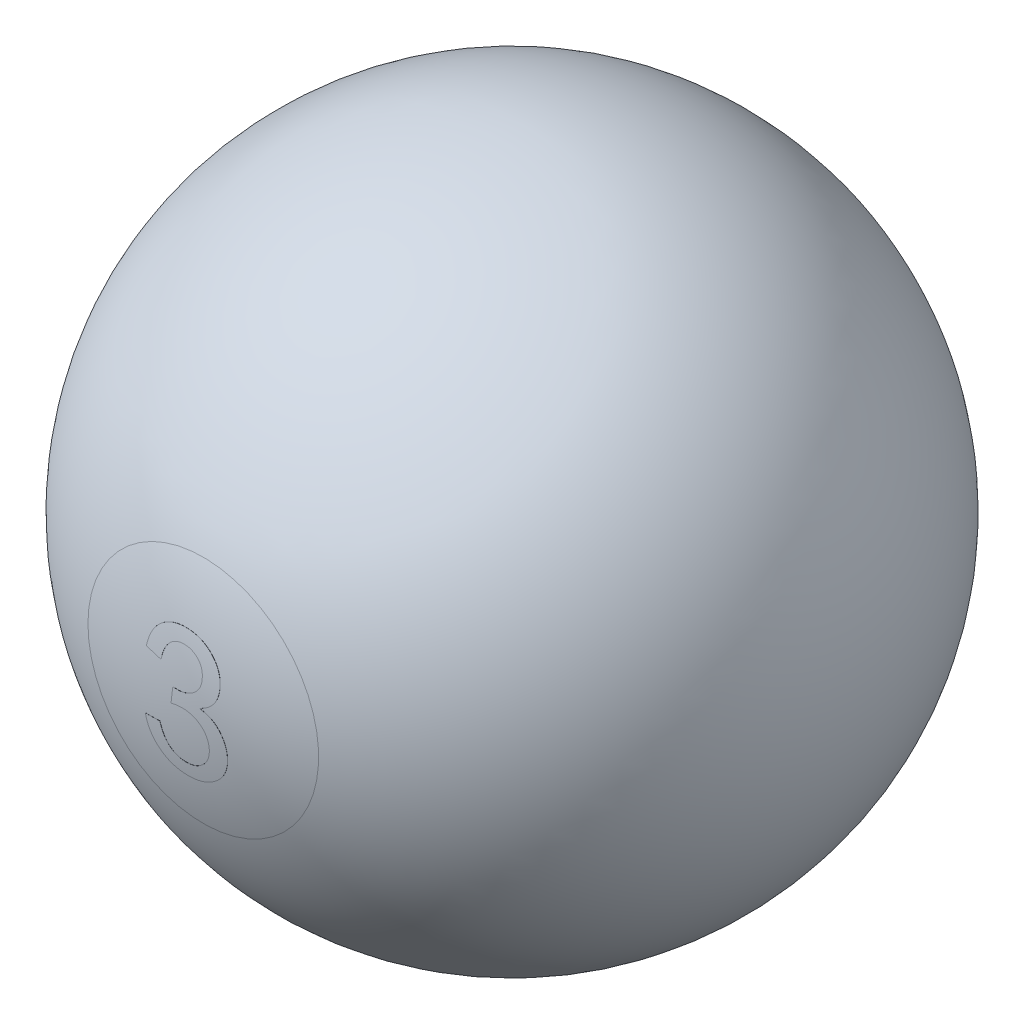
from build123d import *

# Parameters (mm, degrees)
LINEAR_AUSTRAGEN3_REACH      = 51.493
LINEAR_AUSTRAGEN3_END_RADIUS = 28.585
KREISMUSTER3_COUNT           = 2


with BuildPart() as part:
    # Skizze1 → Rotation1 (revolve)
    with BuildSketch(Plane.XY):
        with BuildLine():
            Line((28.575, 0), (-28.575, 0))
            ThreePointArc((-28.575, 0), (0, 28.575), (28.575, 0))
        make_face()
    revolve(axis=Axis((0, 0, 0), (1, 0, 0)))

    # Linear austragen3: up to this sphere (the profile starts inside it)
    linear_austragen3_end = Location((0, 0, 0)) * Sphere(LINEAR_AUSTRAGEN3_END_RADIUS, mode=Mode.PRIVATE)
    # Skizze6 → Linear austragen3 (add, up to the surface)
    with BuildSketch(Plane.XY, mode=Mode.PRIVATE) as linear_austragen3_sk1:
        with BuildLine():
            add(Edge.make_bspline(
                [(1.486607143, 0.244196429), (1.570290846, 0.226271154), (1.734302491, 0.19113942), (1.970249698, 0.115189208), (2.188854111, 0.017961169), (2.394219135, -0.092288216), (2.581031646, -0.226490151), (2.752385067, -0.377491529), (2.90844852, -0.547525786), (3.047629152, -0.733399399), (3.168157757, -0.931709185), (3.277134863, -1.133677188), (3.368260443, -1.340398513), (3.442491837, -1.552434234), (3.500750591, -1.767937707), (3.540630497, -1.98901546), (3.565818594, -2.213554863), (3.569555636, -2.365113228), (3.571428571, -2.441071429)],
                knots=[0, 0, 0, 0, 1.108697074, 2.172934788, 3.204880389, 4.206093888, 5.188037506, 6.178607442, 7.161308294, 8.17378834, 9.182634384, 10.166186428, 11.146234401, 12.106878305, 13.075234477, 14.036023556, 15.015691959, 16, 16, 16, 16], degree=3))
            add(Edge.make_bspline(
                [(3.571428571, -2.441071429), (3.56770147, -2.562502205), (3.56037636, -2.801157814), (3.511490452, -3.150925366), (3.426398543, -3.48322218), (3.306391841, -3.798634686), (3.155305503, -4.099466759), (2.965633684, -4.38086977), (2.745171466, -4.647260314), (2.492218989, -4.891590765), (2.216861126, -5.113637059), (1.925594793, -5.308703555), (1.621341213, -5.475265045), (1.302290047, -5.60900366), (0.970912741, -5.715171617), (0.625276612, -5.787657536), (0.266870575, -5.833797766), (0.023208768, -5.839807355), (-0.100446429, -5.842857143)],
                knots=[0, 0, 0, 0, 1.04348772, 2.050832607, 3.027849651, 3.985018456, 4.945832333, 5.91410632, 6.89488226, 7.912262782, 8.930828092, 9.931024771, 10.921011636, 11.90669419, 12.899588269, 13.906628715, 14.937641313, 16, 16, 16, 16], degree=3))
            add(Edge.make_bspline(
                [(-0.100446429, -5.842857143), (-0.218144064, -5.840477425), (-0.44903966, -5.835808967), (-0.786929113, -5.793464558), (-1.109856738, -5.731477693), (-1.415128419, -5.634940205), (-1.707345617, -5.518245768), (-1.981728621, -5.369805261), (-2.240804482, -5.196133197), (-2.483277149, -4.999123947), (-2.703706669, -4.777067236), (-2.903190801, -4.539065696), (-3.076458866, -4.281225206), (-3.225691588, -4.007942339), (-3.349376564, -3.716017998), (-3.449184887, -3.408339653), (-3.52651497, -3.082903003), (-3.556268383, -2.858819577), (-3.571428571, -2.744642857)],
                knots=[0, 0, 0, 0, 1.097840809, 2.15371029, 3.173627445, 4.161928108, 5.136697, 6.10591076, 7.066857035, 8.04392302, 9.016042305, 9.982391694, 10.93757629, 11.910092237, 12.8837972, 13.891636589, 14.925730372, 16, 16, 16, 16], degree=3))
            Line((-3.571428571, -2.744642857), (-2.142857143, -2.557142857))
            add(Edge.make_bspline(
                [(-2.142857143, -2.557142857), (-2.126107045, -2.644445503), (-2.093538672, -2.814194077), (-2.02776824, -3.057492542), (-1.954776652, -3.284595227), (-1.869816419, -3.494996617), (-1.774932113, -3.688643605), (-1.668762316, -3.864290947), (-1.554863808, -4.024131906), (-1.430150436, -4.167942204), (-1.292644792, -4.29284119), (-1.147370916, -4.403860854), (-0.989913003, -4.495939648), (-0.821560164, -4.569028624), (-0.643783123, -4.627586182), (-0.455562379, -4.670260072), (-0.256583332, -4.694452102), (-0.120599396, -4.698127848), (-0.051339286, -4.7)],
                knots=[0, 0, 0, 0, 1.291404279, 2.510966685, 3.659843074, 4.756126606, 5.80544111, 6.790091746, 7.735305102, 8.654813164, 9.550164339, 10.430304926, 11.307451716, 12.193417606, 13.092677492, 14.023872142, 14.99350733, 16, 16, 16, 16], degree=3))
            add(Edge.make_bspline(
                [(-0.051339286, -4.7), (0.023877964, -4.697489806), (0.171890284, -4.692550252), (0.389983603, -4.664408478), (0.597825922, -4.611366974), (0.798810227, -4.543669529), (0.988464277, -4.449403576), (1.173309153, -4.341874818), (1.344501212, -4.207741588), (1.507352825, -4.059284055), (1.655423225, -3.895658724), (1.785994241, -3.721018638), (1.895381418, -3.53640014), (1.988338472, -3.344595063), (2.05782739, -3.141294723), (2.105291976, -2.929339155), (2.139238416, -2.709264996), (2.141638631, -2.559508597), (2.142857143, -2.483482143)],
                knots=[0, 0, 0, 0, 1.039414619, 2.045357549, 3.030071188, 3.998775674, 4.968788042, 5.950654362, 6.947736046, 7.966204168, 8.99226847, 9.991361361, 10.97322768, 11.952508152, 12.930925156, 13.933238126, 14.950772207, 16, 16, 16, 16], degree=3))
            add(Edge.make_bspline(
                [(2.142857143, -2.483482143), (2.141474454, -2.41044627), (2.138767966, -2.267485195), (2.107625347, -2.057735737), (2.062445835, -1.856785688), (1.994739997, -1.666209773), (1.908375716, -1.485891815), (1.80665663, -1.31318696), (1.68208244, -1.151497477), (1.539955108, -1.001353115), (1.384480527, -0.863090639), (1.216514863, -0.740754627), (1.034734404, -0.641534334), (0.843166031, -0.557258747), (0.639431046, -0.493301311), (0.424460957, -0.445896582), (0.197845615, -0.41930576), (0.043221771, -0.415982335), (-0.035714286, -0.414285714)],
                knots=[0, 0, 0, 0, 1.039520793, 2.03476737, 3.014257368, 3.969595977, 4.908269218, 5.858892987, 6.819157264, 7.808857987, 8.799919747, 9.779409745, 10.761476676, 11.744001019, 12.756257763, 13.797775717, 14.875756186, 16, 16, 16, 16], degree=3))
            add(Edge.make_bspline(
                [(-0.035714286, -0.414285714), (-0.104984474, -0.416194722), (-0.251420825, -0.420230342), (-0.481687804, -0.449270549), (-0.734297186, -0.493716425), (-0.90868392, -0.535344619), (-1, -0.557142857)],
                knots=[0, 0, 0, 0, 0.850710824, 1.798392532, 2.847147604, 4, 4, 4, 4], degree=3))
            Line((-1, -0.557142857), (-0.845982143, 0.728571429))
            add(Edge.make_bspline(
                [(-0.845982143, 0.728571429), (-0.761876551, 0.72836839), (-0.60325117, 0.727985454), (-0.379403772, 0.74173333), (-0.183231824, 0.752225792), (-0.007626033, 0.774848056), (0.157914956, 0.812295289), (0.327821104, 0.863929158), (0.505315292, 0.936791169), (0.690734024, 1.023194653), (0.872388277, 1.131047006), (1.041822358, 1.260701532), (1.191231703, 1.414947968), (1.327036116, 1.586031544), (1.437911447, 1.781640998), (1.515272522, 2.000704643), (1.563590163, 2.241350448), (1.56874597, 2.409131127), (1.571428571, 2.496428571)],
                knots=[0, 0, 0, 0, 1.189476569, 2.243384405, 3.171816706, 3.968247766, 4.74460194, 5.57033408, 6.477275893, 7.456583362, 8.462071333, 9.460038224, 10.464864835, 11.49237022, 12.543383061, 13.628830431, 14.766264109, 16, 16, 16, 16], degree=3))
            add(Edge.make_bspline(
                [(1.571428571, 2.496428571), (1.569370338, 2.560461745), (1.565360927, 2.685197484), (1.544167727, 2.867271175), (1.503136487, 3.037518796), (1.448378782, 3.197930431), (1.372420966, 3.345227956), (1.287099995, 3.485470713), (1.180134263, 3.610843555), (1.020545734, 3.760329663), (0.799579174, 3.918849757), (0.508290966, 4.055725039), (0.196260686, 4.143430127), (-0.019502414, 4.152513561), (-0.129464286, 4.157142857)],
                knots=[0, 0, 0, 0, 0.865373357, 1.68573535, 2.470791522, 3.227405046, 3.969116108, 4.705358259, 5.440226823, 6.186825656, 7.656768999, 9.091088923, 10.517497636, 12, 12, 12, 12], degree=3))
            add(Edge.make_bspline(
                [(-0.129464286, 4.157142857), (-0.192038061, 4.155285475), (-0.315435765, 4.151622652), (-0.495682108, 4.127034606), (-0.66737802, 4.08609723), (-0.830801539, 4.031812176), (-0.98378897, 3.955834616), (-1.129147067, 3.867667383), (-1.264787707, 3.76053228), (-1.390848359, 3.638426042), (-1.507703812, 3.502309173), (-1.61070368, 3.350187724), (-1.704438125, 3.185421321), (-1.786688638, 3.006016959), (-1.858911989, 2.813894998), (-1.915185318, 2.607115365), (-1.96592536, 2.387753601), (-1.98842678, 2.235468228), (-2, 2.157142857)],
                knots=[0, 0, 0, 0, 0.991350633, 1.954978605, 2.875684831, 3.785306039, 4.676327725, 5.576040997, 6.474517762, 7.408263042, 8.35317801, 9.311237712, 10.314294325, 11.353349771, 12.435063167, 13.562077035, 14.746096111, 16, 16, 16, 16], degree=3))
            Line((-2, 2.157142857), (-3.428571429, 2.407142857))
            add(Edge.make_bspline(
                [(-3.428571429, 2.407142857), (-3.406016591, 2.524441772), (-3.361794118, 2.754425616), (-3.263330365, 3.082879366), (-3.154729754, 3.391773608), (-3.017713888, 3.67368983), (-2.868448211, 3.93732013), (-2.691809547, 4.173025281), (-2.502100049, 4.391203941), (-2.288861626, 4.581819654), (-2.06229601, 4.751195748), (-1.823080722, 4.896604196), (-1.575162565, 5.024091558), (-1.313391347, 5.121671395), (-1.043650409, 5.205247902), (-0.761399142, 5.259121787), (-0.468881042, 5.293846245), (-0.270191911, 5.297932235), (-0.169642857, 5.3)],
                knots=[0, 0, 0, 0, 1.196598026, 2.346127519, 3.433890862, 4.474795076, 5.484142389, 6.465743017, 7.422110934, 8.377896977, 9.32664338, 10.254070249, 11.18137714, 12.11636131, 13.050809827, 14.008921245, 14.99239035, 16, 16, 16, 16], degree=3))
            add(Edge.make_bspline(
                [(-0.169642857, 5.3), (-0.058678521, 5.297326205), (0.158705955, 5.292088111), (0.477845991, 5.25392881), (0.782306496, 5.188572818), (1.07382163, 5.100467521), (1.349636909, 4.982667714), (1.612843198, 4.842115751), (1.860702168, 4.67312782), (2.094437396, 4.483296428), (2.303669576, 4.271826856), (2.491960696, 4.050747804), (2.648684643, 3.815214698), (2.776377634, 3.567828581), (2.878541013, 3.309487677), (2.948894078, 3.038884511), (2.993275567, 2.756828759), (2.997731411, 2.565050264), (3, 2.467410714)],
                knots=[0, 0, 0, 0, 1.123761111, 2.201502124, 3.249427722, 4.274422765, 5.280770574, 6.282168429, 7.291699599, 8.314503797, 9.32695594, 10.300518959, 11.251508239, 12.185140702, 13.11575736, 14.058951515, 15.011760414, 16, 16, 16, 16], degree=3))
            add(Edge.make_bspline(
                [(3, 2.467410714), (2.995133948, 2.344338114), (2.985674248, 2.105082606), (2.916666383, 1.759480643), (2.796043157, 1.442129935), (2.629746036, 1.149922468), (2.411711745, 0.887471309), (2.149061668, 0.650327581), (1.838224903, 0.441318617), (1.606507737, 0.330537355), (1.486607143, 0.273214286)],
                knots=[0, 0, 0, 0, 1.039587536, 2.020978204, 2.96205572, 3.896981787, 4.848417189, 5.832040328, 6.87820286, 8, 8, 8, 8], degree=3))
            Line((1.486607143, 0.273214286), (1.486607143, 0.244196429))
        make_face()
    linear_austragen3_tool1 = extrude(linear_austragen3_sk1.sketch, amount=LINEAR_AUSTRAGEN3_REACH, mode=Mode.PRIVATE) & linear_austragen3_end
    linear_austragen3 = linear_austragen3_tool1.solids().sort_by_distance((0.444742, -0.337228, 0))[0]
    add(linear_austragen3)

    # Kreismuster3: Linear austragen3 ×2 about axis
    kreismuster3_axis = Axis((0, 31.4325, 0), (0, -1, 0))
    for i in range(1, KREISMUSTER3_COUNT):
        add(linear_austragen3.rotate(kreismuster3_axis, i * 360 / KREISMUSTER3_COUNT))


solid = part.part
